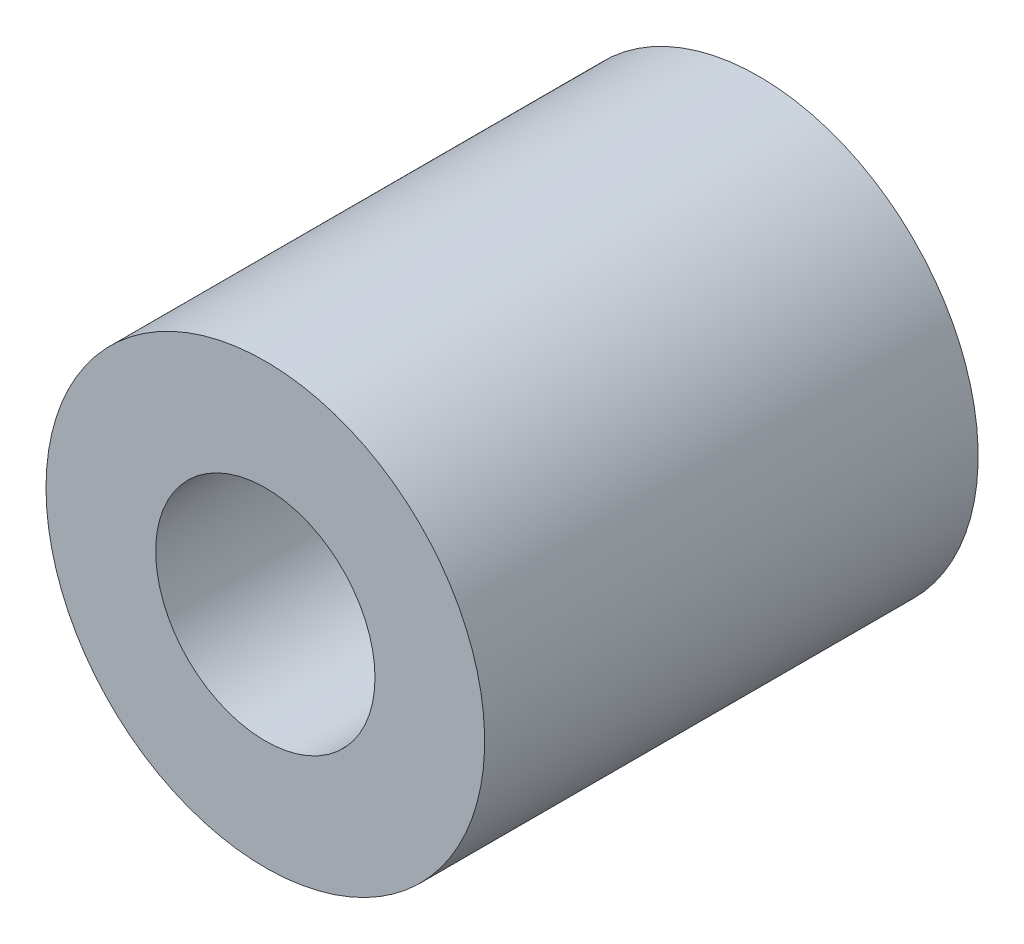
from build123d import *

# Parameters (mm, degrees)
SKETCH_1_R      = 4
SKETCH_1_R_2    = 2
EXTRUDE_1_DEPTH = 9


with BuildPart() as part:
    # ｽｹｯﾁ1 → ﾎﾞｽ - 押し出し1 (new body)
    with BuildSketch(Plane.XY):
        Circle(SKETCH_1_R)
        Circle(SKETCH_1_R_2, mode=Mode.SUBTRACT)
    extrude(amount=EXTRUDE_1_DEPTH)


solid = part.part
